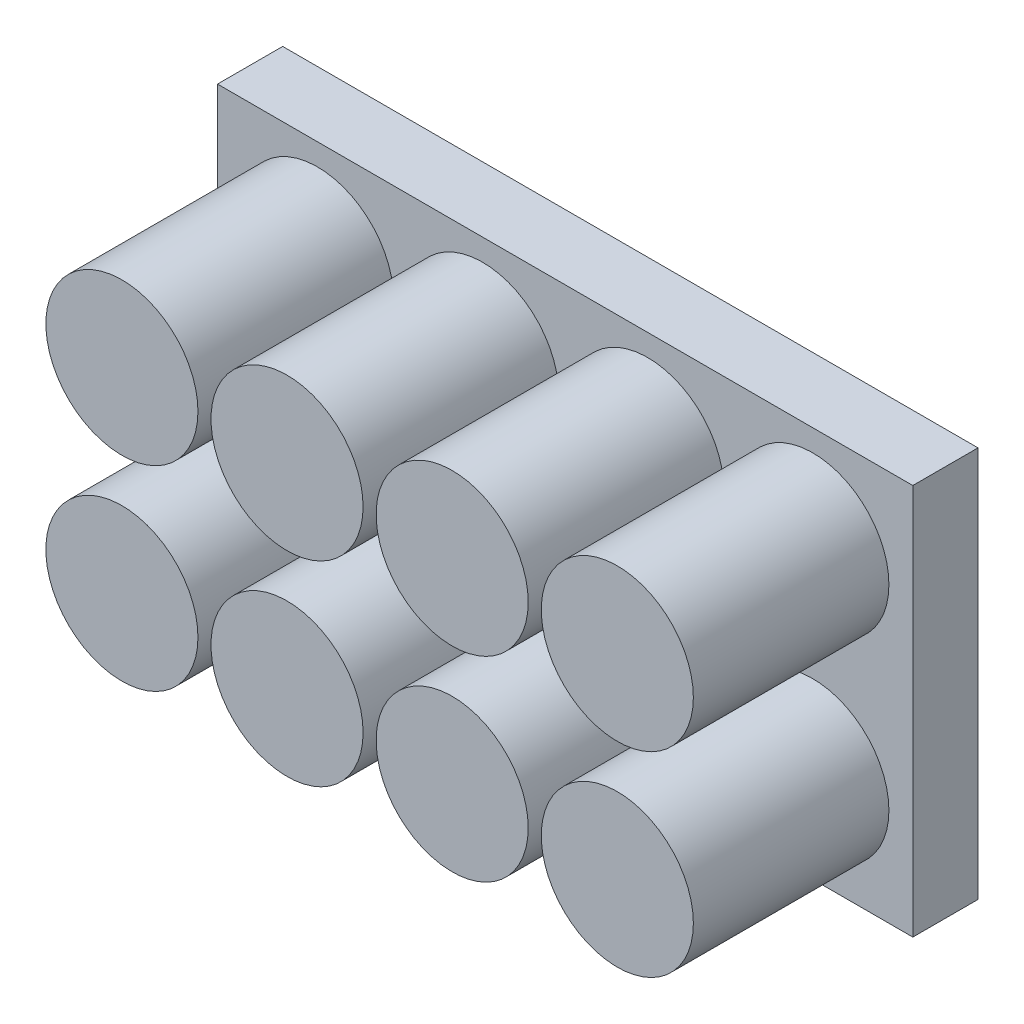
from build123d import *

# Parameters (mm, degrees)
ESQUISSE1_W        = 160
ESQUISSE1_H        = 90
BOSS_EXTRU_1_DEPTH = 15
ESQUISSE2_R        = 17.5
BOSS_EXTRU_2_DEPTH = 45


with BuildPart() as part:
    # Esquisse1 → Boss.-Extru.1 (new body)
    with BuildSketch(Plane.XY):
        with Locations((4.652730082, -12.232142857)):
            Rectangle(ESQUISSE1_W, ESQUISSE1_H)
    extrude(amount=BOSS_EXTRU_1_DEPTH)

    # Esquisse2 → Boss.-Extru.2 (add)
    with BuildSketch(Plane.XY.offset(15)):
        with Locations((-52.347269918, 10.267857143)):
            Circle(ESQUISSE2_R)
        with Locations((-14.347269918, 10.267857143)):
            Circle(ESQUISSE2_R)
        with Locations((23.652730082, 10.267857143)):
            Circle(ESQUISSE2_R)
        with Locations((61.652730082, 10.267857143)):
            Circle(ESQUISSE2_R)
        with Locations((-14.347269918, -34.732142857)):
            Circle(ESQUISSE2_R)
        with Locations((23.652730082, -34.732142857)):
            Circle(ESQUISSE2_R)
        with Locations((61.652730082, -34.732142857)):
            Circle(ESQUISSE2_R)
        with Locations((-52.347269918, -34.732142857)):
            Circle(ESQUISSE2_R)
    extrude(amount=BOSS_EXTRU_2_DEPTH)


solid = part.part
